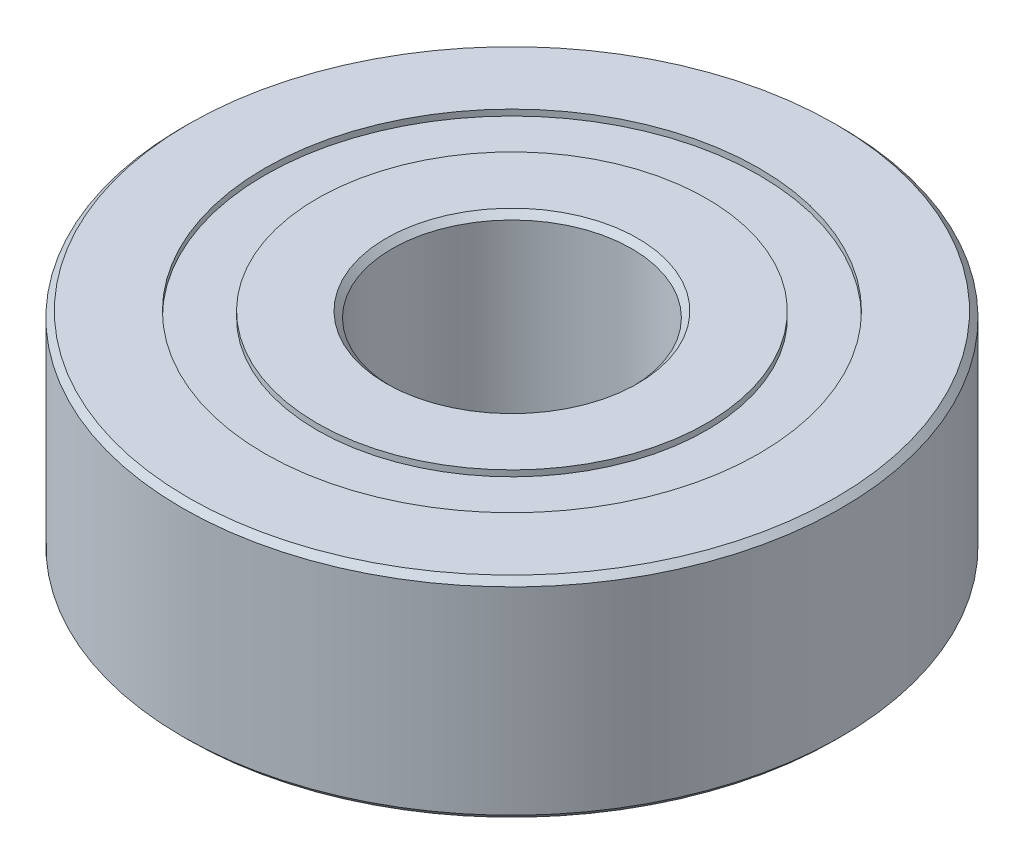
from build123d import *

# Parameters (mm, degrees)
SKETCH1_R           = 11
SKETCH1_R_2         = 4
BOSS_EXTRUDE1_DEPTH = 7
SKETCH2_R           = 8.25
SKETCH2_R_2         = 6.5
CUT_EXTRUDE1_DEPTH  = 0.2
SKETCH3_R           = 8.25
SKETCH3_R_2         = 6.5
CUT_EXTRUDE2_DEPTH  = 0.2
CHAMFER1_SIZE       = 0.2


with BuildPart() as part:
    # Sketch1 → Boss-Extrude1 (new body)
    with BuildSketch(Plane(origin=(0, 0, 0), x_dir=(1, 0, 0), z_dir=(0, 1, 0))):
        Circle(SKETCH1_R)
        Circle(SKETCH1_R_2, mode=Mode.SUBTRACT)
    extrude(amount=BOSS_EXTRUDE1_DEPTH)

    # Sketch2 → Cut-Extrude1 (cut)
    with BuildSketch(Plane(origin=(0, 7, 0), x_dir=(1, 0, 0), z_dir=(0, 1, 0))):
        Circle(SKETCH2_R)
        Circle(SKETCH2_R_2, mode=Mode.SUBTRACT)
    extrude(amount=-CUT_EXTRUDE1_DEPTH, mode=Mode.SUBTRACT)

    # Sketch3 → Cut-Extrude2 (cut)
    with BuildSketch(Plane.XZ):
        Circle(SKETCH3_R)
        Circle(SKETCH3_R_2, mode=Mode.SUBTRACT)
    extrude(amount=-CUT_EXTRUDE2_DEPTH, mode=Mode.SUBTRACT)

    # Chamfer1
    chamfer1_edges = [part.edges().sort_by_distance(p)[0] for p in [
        (-11, 0, 0),
        (-11, 7, 0),
        (-4, 0, 0),
        (-4, 7, 0),
    ]]
    chamfer(chamfer1_edges, length=CHAMFER1_SIZE)


solid = part.part
